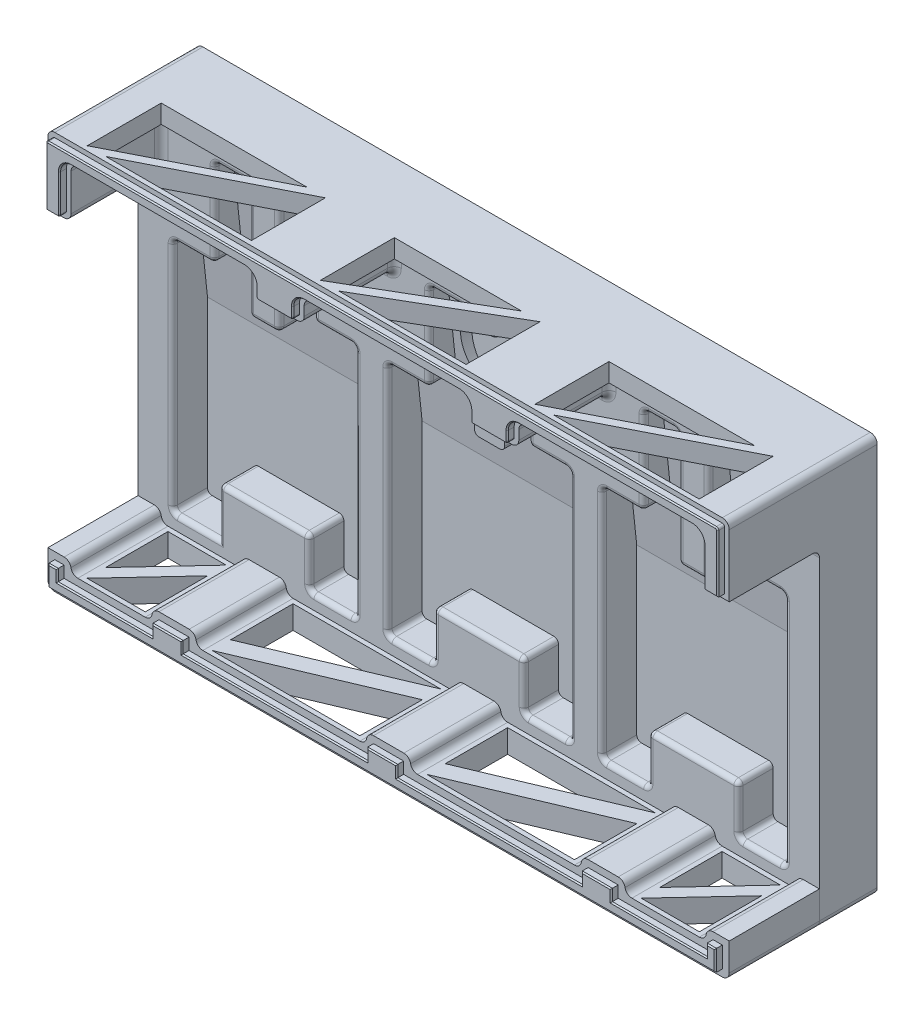
from build123d import *

# Parameters (mm, degrees)
SCHIZZO1_W                    = 294.6
SCHIZZO1_H                    = 172
ESTRUSIONE_ESTRUSIONE1_DEPTH  = 10
ESTRUSIONE_ESTRUSIONE2_DEPTH  = 15
ESTRUSIONE_ESTRUSIONE3_DEPTH  = 264.6
ESTRUSIONE_ESTRUSIONE4_DEPTH  = 39
RACCORDO1_R                   = 3
RACCORDO2_R                   = 2
RACCORDO4_R                   = 2
ESTRUSIONE_ESTRUSIONE5_DEPTH  = 39
RACCORDO8_R                   = 3
ESTRUSIONE_ESTRUSIONE6_DEPTH  = 3
TAGLIO_ESTRUSIONE1_DEPTH      = 4
RACCORDO9_R                   = 3
RACCORDO10_R                  = 3
RACCORDO11_R                  = 3
RACCORDO12_R                  = 3
RACCORDO13_R                  = 3
RACCORDO14_R                  = 3
SMUSSO1_SIZE                  = 0.5
SMUSSO2_SIZE                  = 0.5
TAGLIO_ESTRUSIONE2_DEPTH      = 10
TAGLIO_ESTRUSIONE3_DEPTH      = 10
RACCORDO15_R                  = 3
SCHIZZO15_W                   = 18.505881621
SCHIZZO15_H                   = 6.477058567
TAGLIO_ESTRUSIONE4_DEPTH      = 37
SCHIZZO16_R                   = 17.5
TAGLIO_ESTRUSIONE5_DEPTH      = 37
TAGLIO_ESTRUSIONE5_DEPTH_BACK = 10.35752


with BuildPart() as part:
    # Schizzo1 → Estrusione-Estrusione1 (new body)
    with BuildSketch(Plane.XY):
        Rectangle(SCHIZZO1_W, SCHIZZO1_H)
    extrude(amount=ESTRUSIONE_ESTRUSIONE1_DEPTH)

    # Schizzo2 → Estrusione-Estrusione2 (add)
    with BuildSketch(Plane.XY.offset(10)):
        Polygon((147.3, 86), (-147.3, 86), (-147.3, -86), (-6.32315089, -86), (147.3, -86), align=None)
        Polygon((-53.3, -70), (-73.3, -70), (-73.3, -49), (-112.3, -49), (-112.3, -70), (-132.3, -70), (-132.3, 32), (-114.3, 32), (-114.3, 70), (-99.3, 70), (-99.3, 20), (-86.3, 20), (-86.3, 70), (-71.3, 70), (-71.3, 32), (-53.3, 32), align=None, mode=Mode.SUBTRACT)
        Polygon((-39.5, -69.8088117), (-39.5, 32), (-21.5, 32), (-21.5, 70), (-6.5, 70), (-6.5, 20), (6.5, 20), (6.5, 70), (21.5, 70), (21.5, 32), (39.5, 32), (39.5, -69.8088117), (19.5, -69.8088117), (19.5, -48.8088117), (-19.5, -48.8088117), (-19.5, -69.8088117), align=None, mode=Mode.SUBTRACT)
        Polygon((53.3, -69.8088117), (53.3, 32), (71.3, 32), (71.3, 70), (86.3, 70), (86.3, 20), (99.3, 20), (99.3, 70), (114.3, 70), (114.3, 32), (132.3, 32), (132.3, -69.8088117), (112.3, -69.8088117), (112.3, -48.8088117), (73.3, -48.8088117), (73.3, -69.8088117), align=None, mode=Mode.SUBTRACT)
    extrude(amount=ESTRUSIONE_ESTRUSIONE2_DEPTH)

    # Schizzo4 → Estrusione-Estrusione3 (add)
    with BuildSketch(Plane.ZY.offset(-132.3)):
        Polygon((10, 70), (10, 3.34), (17.12, 70), align=None)
    extrude(amount=ESTRUSIONE_ESTRUSIONE3_DEPTH)

    # Schizzo5 → Estrusione-Estrusione4 (add)
    with BuildSketch(Plane.XY.offset(25)):
        Polygon((-147.3, 86), (-147.3, 56), (-137.3, 56), (-137.3, 78), (-56.3, 78), (-56.3, 68), (-36.5, 68), (-36.5, 78), (36.5, 78), (36.5, 68), (56.3, 68), (56.3, 78), (137.3, 78), (137.3, 56), (147.3, 56), (147.3, 86), align=None)
    extrude(amount=ESTRUSIONE_ESTRUSIONE4_DEPTH)

    # Raccordo1
    raccordo1_edges = [part.edges().sort_by_distance(p)[0] for p in [
        (-142.3, 56, 25),
        (-137.3, 67, 25),
        (-137.3, 56, 44.5),
        (-96.8, 78, 25),
        (-137.3, 78, 44.5),
        (-56.3, 73, 25),
        (-56.3, 78, 44.5),
        (-46.4, 68, 25),
        (-56.3, 68, 44.5),
        (-36.5, 73, 25),
        (-36.5, 68, 44.5),
        (0, 78, 25),
        (-36.5, 78, 44.5),
        (36.5, 73, 25),
        (36.5, 78, 44.5),
        (46.4, 68, 25),
        (36.5, 68, 44.5),
        (56.3, 73, 25),
        (56.3, 68, 44.5),
        (96.8, 78, 25),
        (56.3, 78, 44.5),
        (137.3, 67, 25),
        (137.3, 78, 44.5),
        (142.3, 56, 25),
        (137.3, 56, 44.5),
        (-147.3, 86, 32),
        (147.3, 86, 32),
    ]]
    fillet(raccordo1_edges, radius=RACCORDO1_R)

    # Raccordo2
    raccordo2_edges = [part.edges().sort_by_distance(p)[0] for p in [
        (-86.3, 45, 25),
        (-86.3, 20, 18.389732973),
        (-86.3, 70, 21.06),
        (-71.3, 70, 21.06),
        (-62.3, 32, 25),
        (-71.3, 32, 19.03059706),
        (-53.3, 32, 19.03059706),
        (-63.3, -70, 25),
        (-53.3, -70, 17.5),
        (-73.3, -59.5, 25),
        (-73.3, -70, 17.5),
        (-92.8, -49, 25),
        (-73.3, -49, 17.5),
        (-112.3, -49, 17.5),
        (-122.3, -70, 25),
        (-132.3, -19, 25),
        (-132.3, -70, 17.5),
        (-132.3, 32, 19.03059706),
        (-114.3, 51, 25),
        (-114.3, 32, 19.03059706),
        (-114.3, 70, 21.06),
        (-99.3, 70, 21.06),
        (-99.3, 20, 18.389732973),
        (-78.8, 70, 25),
        (-71.3, 51, 25),
        (-53.3, -19, 25),
        (-112.3, -59.5, 25),
        (-123.3, 32, 25),
        (-106.8, 70, 25),
        (-99.3, 45, 25),
        (-92.8, 20, 25),
    ]]
    fillet(raccordo2_edges, radius=RACCORDO2_R)

    # Raccordo4
    raccordo4_edges = [part.edges().sort_by_distance(p)[0] for p in [
        (86.3, 70, 21.06),
        (86.3, 20, 18.389732973),
        (99.3, 45, 25),
        (99.3, 20, 18.389732973),
        (99.3, 70, 21.06),
        (114.3, 70, 21.06),
        (123.3, 32, 25),
        (114.3, 32, 19.03059706),
        (132.3, 32, 19.03059706),
        (122.3, -69.8088117, 25),
        (132.3, -69.8088117, 17.5),
        (112.3, -59.3088117, 25),
        (112.3, -69.8088117, 17.5),
        (92.8, -48.8088117, 25),
        (112.3, -48.8088117, 17.5),
        (73.3, -48.8088117, 17.5),
        (63.3, -69.8088117, 25),
        (73.3, -69.8088117, 17.5),
        (53.3, -18.90440585, 25),
        (53.3, -69.8088117, 17.5),
        (53.3, 32, 19.03059706),
        (71.3, 51, 25),
        (71.3, 32, 19.03059706),
        (-6.5, 70, 21.06),
        (-6.5, 20, 18.389732973),
        (6.5, 45, 25),
        (6.5, 20, 18.389732973),
        (6.5, 70, 21.06),
        (21.5, 70, 21.06),
        (30.5, 32, 25),
        (21.5, 32, 19.03059706),
        (39.5, 32, 19.03059706),
        (29.5, -69.8088117, 25),
        (39.5, -69.8088117, 17.5),
        (19.5, -59.3088117, 25),
        (19.5, -69.8088117, 17.5),
        (0, -48.8088117, 25),
        (19.5, -48.8088117, 17.5),
        (-19.5, -48.8088117, 17.5),
        (-29.5, -69.8088117, 25),
        (-19.5, -69.8088117, 17.5),
        (-39.5, -18.90440585, 25),
        (-39.5, -69.8088117, 17.5),
        (-39.5, 32, 19.03059706),
        (-21.5, 51, 25),
        (-21.5, 32, 19.03059706),
        (-21.5, 70, 21.06),
        (71.3, 70, 21.06),
        (-6.5, 45, 25),
        (0, 20, 25),
        (14, 70, 25),
        (21.5, 51, 25),
        (39.5, -18.90440585, 25),
        (-19.5, -59.3088117, 25),
        (-30.5, 32, 25),
        (-14, 70, 25),
        (86.3, 45, 25),
        (92.8, 20, 25),
        (106.8, 70, 25),
        (114.3, 51, 25),
        (132.3, -18.90440585, 25),
        (73.3, -59.3088117, 25),
        (62.3, 32, 25),
        (78.8, 70, 25),
    ]]
    fillet(raccordo4_edges, radius=RACCORDO4_R)

    # Raccordo8
    raccordo8_edges = [part.edges().sort_by_distance(p)[0] for p in [
        (147.3, -86, 12.5),
        (-147.3, -86, 12.5),
    ]]
    fillet(raccordo8_edges, radius=RACCORDO8_R)

    # Schizzo10 → Estrusione-Estrusione6 (add)
    with BuildSketch(Plane.XY.offset(64)):
        with BuildLine():
            Line((-38.5, 71), (-38.5, 75))
            ThreePointArc((-38.5, 75), (-37.035533906, 78.535533906), (-33.5, 80))
            Line((-33.5, 80), (33.5, 80))
            ThreePointArc((33.5, 80), (37.035533906, 78.535533906), (38.5, 75))
            Line((38.5, 75), (38.5, 71))
            ThreePointArc((38.5, 71), (38.792893219, 70.292893219), (39.5, 70))
            Line((39.5, 70), (53.3, 70))
            ThreePointArc((53.3, 70), (54.007106781, 70.292893219), (54.3, 71))
            Line((54.3, 71), (54.3, 75))
            ThreePointArc((54.3, 75), (55.764466094, 78.535533906), (59.3, 80))
            Line((59.3, 80), (134.3, 80))
            ThreePointArc((134.3, 80), (137.835533906, 78.535533906), (139.3, 75))
            Line((139.3, 75), (139.3, 59))
            ThreePointArc((139.3, 59), (139.592893219, 58.292893219), (140.3, 58))
            Line((140.3, 58), (145.3, 58))
            Line((145.3, 58), (145.3, 83))
            ThreePointArc((145.3, 83), (145.007106781, 83.707106781), (144.3, 84))
            Line((144.3, 84), (-144.3, 84))
            ThreePointArc((-144.3, 84), (-145.007106781, 83.707106781), (-145.3, 83))
            Line((-145.3, 83), (-145.3, 58))
            Line((-145.3, 58), (-140.3, 58))
            ThreePointArc((-140.3, 58), (-139.592893219, 58.292893219), (-139.3, 59))
            Line((-139.3, 59), (-139.3, 75))
            ThreePointArc((-139.3, 75), (-137.835533906, 78.535533906), (-134.3, 80))
            Line((-134.3, 80), (-59.3, 80))
            ThreePointArc((-59.3, 80), (-55.764466094, 78.535533906), (-54.3, 75))
            Line((-54.3, 75), (-54.3, 71))
            ThreePointArc((-54.3, 71), (-54.007106781, 70.292893219), (-53.3, 70))
            Line((-53.3, 70), (-39.5, 70))
            ThreePointArc((-39.5, 70), (-38.792893219, 70.292893219), (-38.5, 71))
        make_face()
        Polygon((140.3, -74), (140.3, -79), (99.3, -79), (99.3, -74), (86.3, -74), (86.3, -79), (6.5, -79), (6.5, -74), (-6.5, -74), (-6.5, -79), (-86.3, -79), (-86.3, -74), (-99.3, -74), (-99.3, -79), (-140.3, -79), (-140.3, -74), (-144.3, -74), (-144.3, -83), (144.3, -83), (144.3, -74), align=None)
    extrude(amount=ESTRUSIONE_ESTRUSIONE6_DEPTH)

    # Schizzo11 → Taglio-Estrusione1 (cut)
    with BuildSketch(Plane.XY):
        with BuildLine():
            Line((-144.3, -83), (144.3, -83))
            Line((144.3, -83), (144.3, -74))
            Line((144.3, -74), (140.3, -74))
            ThreePointArc((140.3, -74), (138.256903563, -77.582575695), (134.383920217, -79))
            Line((134.383920217, -79), (107.216079783, -79))
            ThreePointArc((107.216079783, -79), (103.343096437, -77.582575695), (101.3, -74))
            Line((101.3, -74), (84.3, -74))
            ThreePointArc((84.3, -74), (82.256903563, -77.582575695), (78.383920217, -79))
            Line((78.383920217, -79), (14.416079783, -79))
            ThreePointArc((14.416079783, -79), (10.543096437, -77.582575695), (8.5, -74))
            Line((8.5, -74), (-8.5, -74))
            ThreePointArc((-8.5, -74), (-10.543096437, -77.582575695), (-14.416079783, -79))
            Line((-14.416079783, -79), (-78.383920217, -79))
            ThreePointArc((-78.383920217, -79), (-82.256903563, -77.582575695), (-84.3, -74))
            Line((-84.3, -74), (-101.3, -74))
            ThreePointArc((-101.3, -74), (-103.343096437, -77.582575695), (-107.216079783, -79))
            Line((-107.216079783, -79), (-134.383920217, -79))
            ThreePointArc((-134.383920217, -79), (-138.256903563, -77.582575695), (-140.3, -74))
            Line((-140.3, -74), (-144.3, -74))
            Line((-144.3, -74), (-144.3, -83))
        make_face()
        with BuildLine():
            Line((140.3, 58), (144.3, 58))
            ThreePointArc((144.3, 58), (145.007106781, 58.292893219), (145.3, 59))
            Line((145.3, 59), (145.3, 83))
            ThreePointArc((145.3, 83), (145.007106781, 83.707106781), (144.3, 84))
            Line((144.3, 84), (-144.3, 84))
            ThreePointArc((-144.3, 84), (-145.007106781, 83.707106781), (-145.3, 83))
            Line((-145.3, 83), (-145.3, 59))
            ThreePointArc((-145.3, 59), (-145.007106781, 58.292893219), (-144.3, 58))
            Line((-144.3, 58), (-140.3, 58))
            ThreePointArc((-140.3, 58), (-139.592893219, 58.292893219), (-139.3, 59))
            Line((-139.3, 59), (-139.3, 75))
            ThreePointArc((-139.3, 75), (-137.835533906, 78.535533906), (-134.3, 80))
            Line((-134.3, 80), (-59.3, 80))
            ThreePointArc((-59.3, 80), (-55.764466094, 78.535533906), (-54.3, 75))
            Line((-54.3, 75), (-54.3, 71))
            ThreePointArc((-54.3, 71), (-54.007106781, 70.292893219), (-53.3, 70))
            Line((-53.3, 70), (-39.5, 70))
            ThreePointArc((-39.5, 70), (-38.792893219, 70.292893219), (-38.5, 71))
            Line((-38.5, 71), (-38.5, 75))
            ThreePointArc((-38.5, 75), (-37.035533906, 78.535533906), (-33.5, 80))
            Line((-33.5, 80), (33.5, 80))
            ThreePointArc((33.5, 80), (37.035533906, 78.535533906), (38.5, 75))
            Line((38.5, 75), (38.5, 71))
            ThreePointArc((38.5, 71), (38.792893219, 70.292893219), (39.5, 70))
            Line((39.5, 70), (53.3, 70))
            ThreePointArc((53.3, 70), (54.007106781, 70.292893219), (54.3, 71))
            Line((54.3, 71), (54.3, 75))
            ThreePointArc((54.3, 75), (55.764466094, 78.535533906), (59.3, 80))
            Line((59.3, 80), (134.3, 80))
            ThreePointArc((134.3, 80), (137.835533906, 78.535533906), (139.3, 75))
            Line((139.3, 75), (139.3, 59))
            ThreePointArc((139.3, 59), (139.592893219, 58.292893219), (140.3, 58))
        make_face()
    extrude(amount=TAGLIO_ESTRUSIONE1_DEPTH, mode=Mode.SUBTRACT)

    # Smusso1
    smusso1_edges = [part.edges().sort_by_distance(p)[0] for p in [
        (119.8, -79, 67),
        (99.3, -76.5, 67),
        (92.8, -74, 67),
        (86.3, -76.5, 67),
        (46.4, -79, 67),
        (6.5, -76.5, 67),
        (0, -74, 67),
        (-6.5, -76.5, 67),
        (-46.4, -79, 67),
        (-86.3, -76.5, 67),
        (142.3, -74, 67),
        (-92.8, -74, 67),
        (-99.3, -76.5, 67),
        (-119.8, -79, 67),
        (-140.3, -76.5, 67),
        (-142.3, -74, 67),
        (-144.3, -78.5, 67),
        (0, -83, 67),
        (144.3, -78.5, 67),
        (140.3, -76.5, 67),
    ]]
    chamfer(smusso1_edges, length=SMUSSO1_SIZE)

    # Smusso2
    smusso2_edges = [part.edges().sort_by_distance(p)[0] for p in [
        (145.3, 70.5, 67),
        (145.007106781, 83.707106781, 67),
        (0, 84, 67),
        (-145.007106781, 83.707106781, 67),
        (-145.3, 70.5, 67),
        (-142.8, 58, 67),
        (-139.592893219, 58.292893219, 67),
        (-139.3, 67, 67),
        (-137.835533906, 78.535533906, 67),
        (-96.8, 80, 67),
        (-55.764466094, 78.535533906, 67),
        (-54.3, 73, 67),
        (-54.007106781, 70.292893219, 67),
        (-46.4, 70, 67),
        (-38.792893219, 70.292893219, 67),
        (-38.5, 73, 67),
        (-37.035533906, 78.535533906, 67),
        (0, 80, 67),
        (37.035533906, 78.535533906, 67),
        (38.5, 73, 67),
        (38.792893219, 70.292893219, 67),
        (46.4, 70, 67),
        (54.007106781, 70.292893219, 67),
        (54.3, 73, 67),
        (55.764466094, 78.535533906, 67),
        (96.8, 80, 67),
        (137.835533906, 78.535533906, 67),
        (139.3, 67, 67),
        (139.592893219, 58.292893219, 67),
        (142.8, 58, 67),
    ]]
    chamfer(smusso2_edges, length=SMUSSO2_SIZE)

    # Schizzo12 → Taglio-Estrusione2 (cut)
    with BuildSketch(Plane.XZ.offset(-78)):
        Polygon((-132.3, 30), (-132.3, 62), (-69.3, 30), align=None)
        Polygon((-124.3, 62), (-61.3, 62), (-61.3, 30), align=None)
        Polygon((132.3, 62), (132.3, 30), (69.3, 62), align=None)
        Polygon((61.3, 62), (124.3, 30), (61.3, 30), align=None)
        Polygon((-31.5, 30), (23.5, 30), (-31.5, 62), align=None)
        Polygon((-23.5, 62), (31.5, 62), (31.5, 30), align=None)
    extrude(amount=-TAGLIO_ESTRUSIONE2_DEPTH, mode=Mode.SUBTRACT)

    # Schizzo15 → Taglio-Estrusione4 (cut)
    with BuildSketch(Plane.XZ.offset(-20)):
        with Locations((0.42892632, 23.596048806)):
            Rectangle(SCHIZZO15_W, SCHIZZO15_H)
    extrude(amount=-TAGLIO_ESTRUSIONE4_DEPTH, mode=Mode.SUBTRACT)

    # Schizzo16 → Taglio-Estrusione5 (cut, two sides)
    with BuildSketch(Plane.XY.offset(20.357519522)) as taglio_estrusione5_sk:
        with Locations((-0.5, 48.5)):
            Circle(SCHIZZO16_R)
    extrude(amount=TAGLIO_ESTRUSIONE5_DEPTH, mode=Mode.SUBTRACT)
    extrude(taglio_estrusione5_sk.sketch, amount=-TAGLIO_ESTRUSIONE5_DEPTH_BACK, mode=Mode.SUBTRACT)


with BuildPart() as body_2:
    # Schizzo8 → Estrusione-Estrusione5 (new body)
    with BuildSketch(Plane.XY.offset(25)):
        Polygon((-147.3, -86), (-147.3, -71), (-137.3, -71), (-137.3, -76), (-102.3, -76), (-102.3, -71), (-83.3, -71), (-83.3, -76), (-9.5, -76), (-9.5, -71), (9.5, -71), (9.5, -76), (83.3, -76), (83.3, -71), (102.3, -71), (102.3, -76), (137.3, -76), (137.3, -71), (147.3, -71), (147.3, -86), align=None)
    extrude(amount=ESTRUSIONE_ESTRUSIONE5_DEPTH)

    # Raccordo9
    raccordo9_edges = [body_2.edges().sort_by_distance(p)[0] for p in [
        (9.5, -76, 44.5),
        (-9.5, -71, 44.5),
        (-83.3, -76, 44.5),
        (-102.3, -71, 44.5),
    ]]
    fillet(raccordo9_edges, radius=RACCORDO9_R)

    # Raccordo10
    raccordo10_edges = [body_2.edges().sort_by_distance(p)[0] for p in [
        (-9.5, -76, 44.5),
        (-137.3, -71, 44.5),
        (-83.3, -71, 44.5),
        (-102.3, -76, 44.5),
    ]]
    fillet(raccordo10_edges, radius=RACCORDO10_R)

    # Raccordo11
    raccordo11_edges = [body_2.edges().sort_by_distance(p)[0] for p in [
        (-137.3, -76, 44.5),
        (137.3, -71, 44.5),
    ]]
    fillet(raccordo11_edges, radius=RACCORDO11_R)

    # Raccordo12
    raccordo12_edges = [body_2.edges().sort_by_distance(p)[0] for p in [
        (137.3, -76, 44.5),
        (102.3, -71, 44.5),
    ]]
    fillet(raccordo12_edges, radius=RACCORDO12_R)

    # Raccordo13
    raccordo13_edges = [body_2.edges().sort_by_distance(p)[0] for p in [
        (102.3, -76, 44.5),
        (9.5, -71, 44.5),
        (83.3, -71, 44.5),
    ]]
    fillet(raccordo13_edges, radius=RACCORDO13_R)

    # Raccordo14
    raccordo14_edges = [body_2.edges().sort_by_distance(p)[0] for p in [
        (-147.3, -86, 44.5),
        (147.3, -86, 44.5),
    ]]
    fillet(raccordo14_edges, radius=RACCORDO14_R)

    # Schizzo14 → Taglio-Estrusione3 (cut)
    with BuildSketch(Plane(origin=(0, -76, 0), x_dir=(1, 0, 0), z_dir=(0, 1, 0))):
        Polygon((-78.3, -27), (-14.416079783, -27), (-78.3, -54), align=None)
        Polygon((-78.3, -62), (-14.416079783, -35), (-14.416079783, -62), align=None)
        Polygon((78.383920217, -62), (14.5, -62), (78.383920217, -35), align=None)
        Polygon((78.383920217, -27), (14.5, -54), (14.5, -27), align=None)
        Polygon((107.216079783, -27), (132.383920217, -27), (107.216079783, -54), align=None)
        Polygon((132.383920217, -35), (132.383920217, -62), (107.216079783, -62), align=None)
        Polygon((-132.383920217, -27), (-107.216079783, -27), (-132.383920217, -54), align=None)
        Polygon((-132.383920217, -62), (-107.216079783, -35), (-107.216079783, -62), align=None)
    extrude(amount=-TAGLIO_ESTRUSIONE3_DEPTH, mode=Mode.SUBTRACT)

    # Raccordo15
    raccordo15_edges = [body_2.edges().sort_by_distance(p)[0] for p in [
        (83.3, -76, 44.5),
    ]]
    fillet(raccordo15_edges, radius=RACCORDO15_R)


solid = Compound([part.part, body_2.part])
